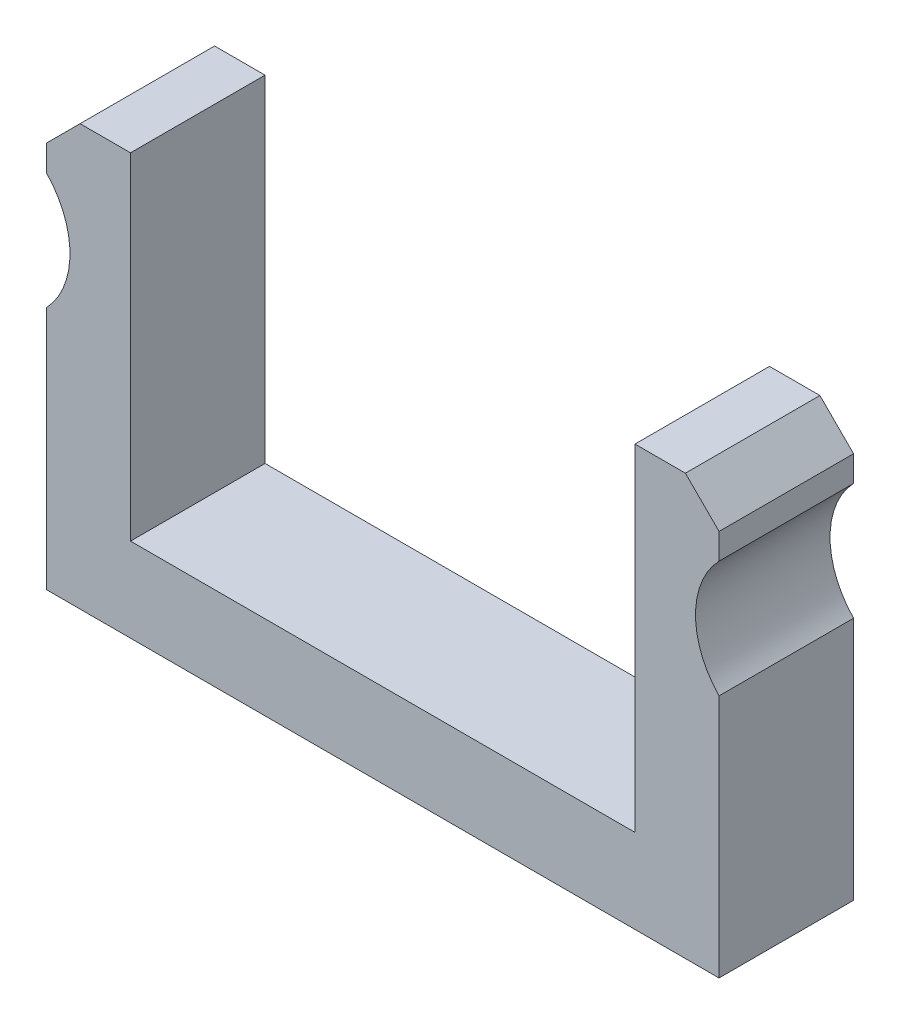
from build123d import *

# Parameters (mm, degrees)
BOSS_EXTRUDE1_DEPTH = 10.16
SKETCH2_R           = 6.35
CUT_EXTRUDE1_DEPTH  = 25.4
CHAMFER1_SIZE       = 2.54
CHAMFER2_SIZE       = 2.54


with BuildPart() as part:
    # Sketch1 → Boss-Extrude1 (new body)
    with BuildSketch(Plane.XY):
        Polygon((-34.042504308, -19.37463512), (16.757495692, -19.37463512), (16.757495692, 12.37536488), (10.407495692, 12.37536488), (10.407495692, -13.02463512), (-27.692504308, -13.02463512), (-27.692504308, 12.37536488), (-34.042504308, 12.37536488), align=None)
    extrude(amount=BOSS_EXTRUDE1_DEPTH)

    # Sketch2 → Cut-Extrude1 (cut)
    with BuildSketch(Plane.XY.offset(10.16)):
        with Locations((-38.614504308, 3.48536488)):
            Circle(SKETCH2_R)
        with Locations((21.329495692, 3.48536488)):
            Circle(SKETCH2_R)
    extrude(amount=-CUT_EXTRUDE1_DEPTH, mode=Mode.SUBTRACT)

    # Chamfer1
    chamfer1_edges = [part.edges().sort_by_distance(p)[0] for p in [
        (16.757495692, 12.37536488, 5.08),
    ]]
    chamfer(chamfer1_edges, length=CHAMFER1_SIZE)

    # Chamfer2
    chamfer2_edges = [part.edges().sort_by_distance(p)[0] for p in [
        (-34.042504308, 12.37536488, 5.08),
    ]]
    chamfer(chamfer2_edges, length=CHAMFER2_SIZE)


solid = part.part
